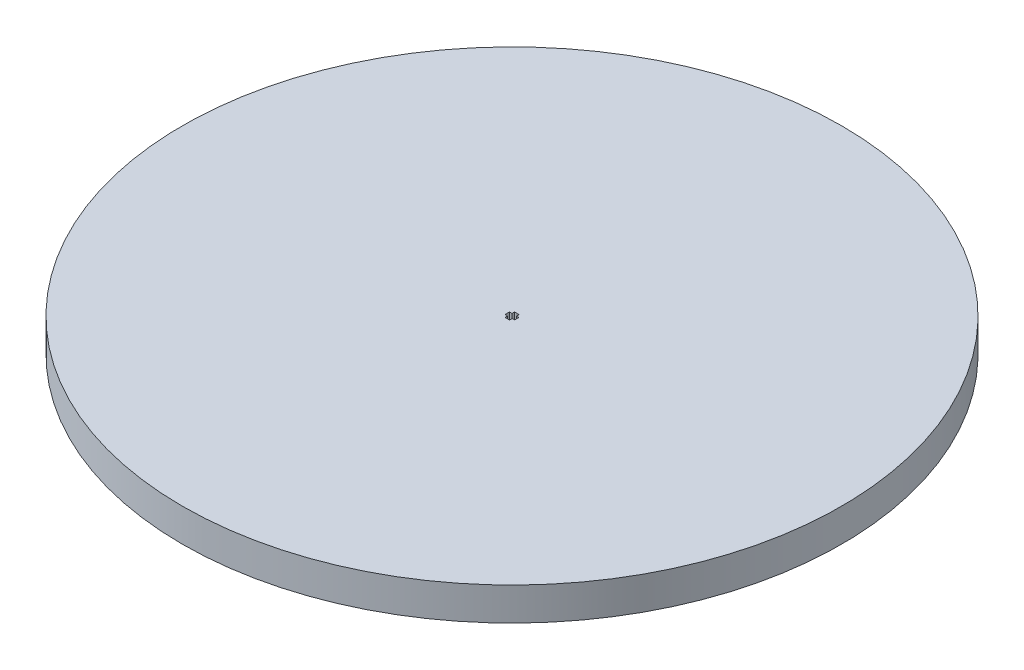
from build123d import *

# Parameters (mm, degrees)
SKETCH1_R           = 50
BOSS_EXTRUDE1_DEPTH = 5


with BuildPart() as part:
    # Sketch1 → Boss-Extrude1 (new body)
    with BuildSketch(Plane(origin=(0, 0, 0), x_dir=(1, 0, 0), z_dir=(0, 1, 0))):
        Circle(SKETCH1_R)
        Polygon((0.012163769, -0.721880139), (-0.338076022, -0.721880139), (-0.338076022, -0.338076022), (-0.721880139, -0.338076022), (-0.721880139, -0.012163769), (-0.721880139, 0.012163769), (-0.721880139, 0.338076022), (-0.338076022, 0.338076022), (-0.338076022, 0.721880139), (0.012163769, 0.721880139), (0.362204732, 0.710080322), (0.34927411, 0.326494088), (0.732860345, 0.313563466), (0.722290178, 0), (0.732860345, -0.313563466), (0.34927411, -0.326494088), (0.362204732, -0.710080322), align=None, mode=Mode.SUBTRACT)
    extrude(amount=BOSS_EXTRUDE1_DEPTH)


solid = part.part
